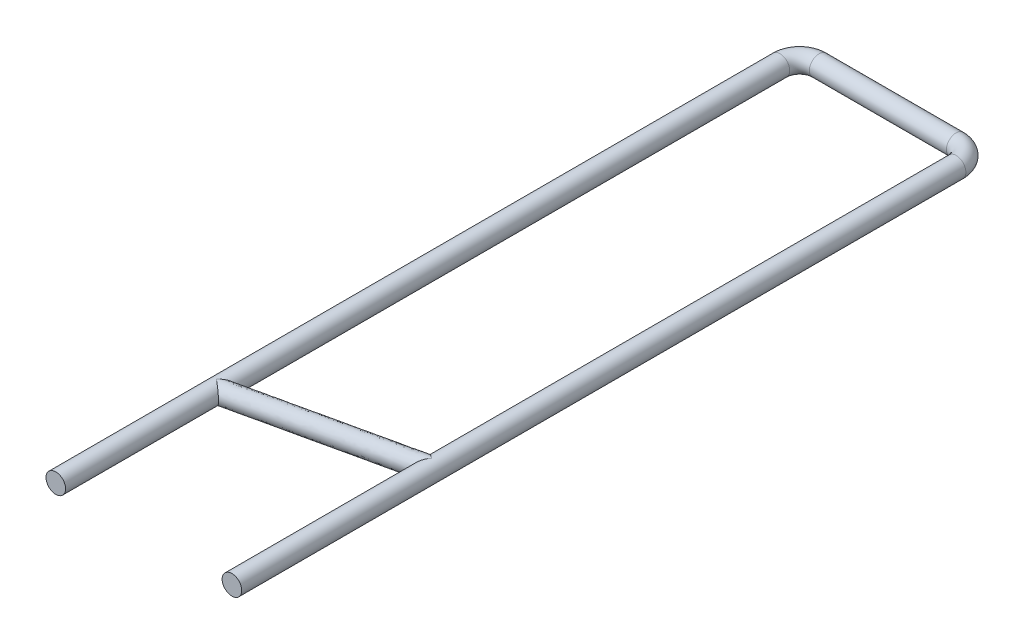
from build123d import *

# Parameters (mm, degrees)
SKETCH_1_R = 0.5
SKETCH_3_R = 0.5


with BuildPart() as part:
    # 掃出1: sweep along a path in 草圖2
    with BuildLine(Plane(origin=(0, 0, 0), x_dir=(1, 0, 0), z_dir=(0, 1, 0))) as sweep_1_path:
        Line((-4.5, -38), (-4.5, -1))
        ThreePointArc((-4.5, -1), (-4.207106781, -0.292893219), (-3.5, 0))
        Line((-3.5, 0), (3.5, 0))
        ThreePointArc((3.5, 0), (4.207106781, -0.292893219), (4.5, -1))
        Line((4.5, -1), (4.5, -38))
    # 草圖1 → 掃出1 (sweep)
    with BuildSketch(Plane.XY.offset(38)):
        with Locations((-4.5, 0)):
            Circle(SKETCH_1_R)
    sweep(path=sweep_1_path.line)

    # 掃出2: sweep along a path in 草圖4
    with BuildLine(Plane(origin=(0, 0, 0), x_dir=(1, 0, 0), z_dir=(0, 1, 0))) as sweep_2_path:
        Line((-4.5, -29.8), (4.5, -27.8))
    # 草圖3 → 掃出2 (sweep)
    with BuildSketch(Plane(origin=(4.5, 0, 0), x_dir=(0, 0, -1), z_dir=(1, 0, 0))):
        with Locations((-27.8, 0)):
            Circle(SKETCH_3_R)
    sweep(path=sweep_2_path.line)


solid = part.part
